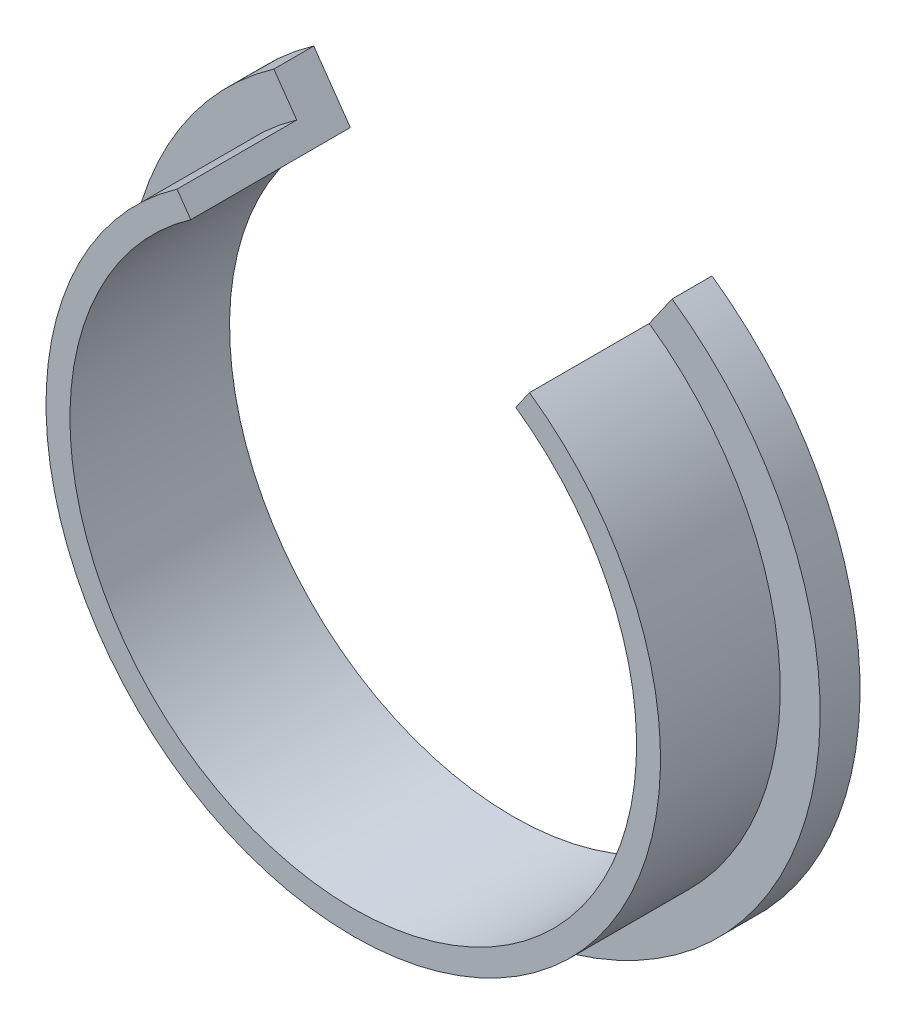
from build123d import *

# Parameters (mm, degrees)
ESBO_O1_R                = 43.5
RESSALTO_EXTRUS_O1_DEPTH = 5
ESBO_O2_R                = 38.5
RESSALTO_EXTRUS_O2_DEPTH = 15
ESBO_O3_R                = 35.5
CORTE_EXTRUS_O1_DEPTH    = 21
CORTE_EXTRUS_O2_DEPTH    = 21


with BuildPart() as part:
    # Esboço1 → Ressalto-extrusão1 (new body)
    with BuildSketch(Plane.XY):
        Circle(ESBO_O1_R)
    extrude(amount=RESSALTO_EXTRUS_O1_DEPTH)

    # Esboço2 → Ressalto-extrusão2 (add)
    with BuildSketch(Plane.XY.offset(5)):
        Circle(ESBO_O2_R)
    extrude(amount=RESSALTO_EXTRUS_O2_DEPTH)

    # Esboço3 → Corte-extrusão1 (cut, through all)
    with BuildSketch(Plane.XY.offset(20)):
        Circle(ESBO_O3_R)
    extrude(amount=-CORTE_EXTRUS_O1_DEPTH, mode=Mode.SUBTRACT)

    # Esboço4 → Corte-extrusão2 (cut, through all)
    with BuildSketch(Plane(origin=(0, 0, 0), x_dir=(-1, 0, 0), z_dir=(0, 0, -1))):
        with BuildLine():
            Line((0, 0), (24.950574981, 35.633113927))
            ThreePointArc((24.950574981, 35.633113927), (0, 43.5), (-24.950574981, 35.633113927))
            Line((-24.950574981, 35.633113927), (0, 0))
        make_face()
    extrude(amount=-CORTE_EXTRUS_O2_DEPTH, mode=Mode.SUBTRACT)


solid = part.part
